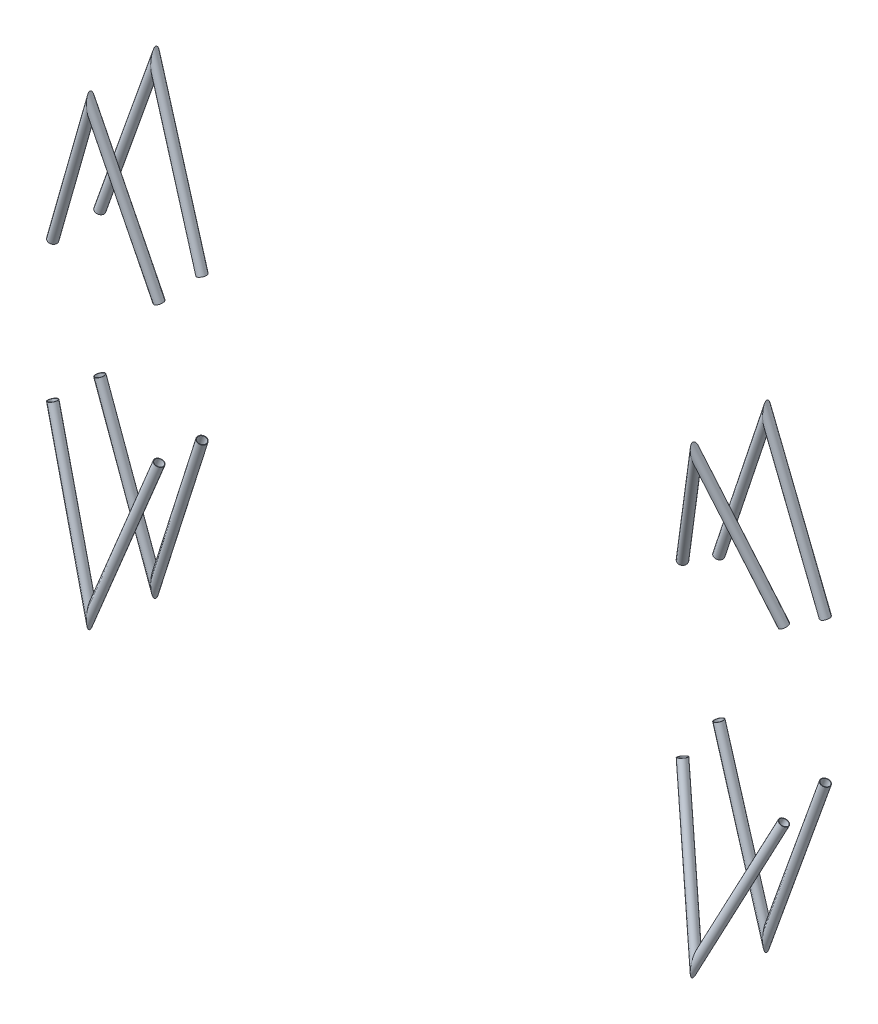
from build123d import *

# Parameters (mm, degrees)
SKETCH1_R                                   = 12.5
SKETCH1_R_2                                 = 11.3
SIZE_C_TUBING_FSAE_SIZE_C_TUBING_1_DEPTH    = 505.010497452
SKETCH1_ON_SEGMENT_2_R                      = 12.5
SKETCH1_ON_SEGMENT_2_R_2                    = 11.3
SIZE_C_TUBING_FSAE_SIZE_C_TUBING_1_2_DEPTH  = 511.58362987
SKETCH1_ON_SEGMENT_3_R                      = 12.5
SKETCH1_ON_SEGMENT_3_R_2                    = 11.3
SIZE_C_TUBING_FSAE_SIZE_C_TUBING_1_3_DEPTH  = 464.446173361
SKETCH1_ON_SEGMENT_4_R                      = 12.5
SKETCH1_ON_SEGMENT_4_R_2                    = 11.3
SIZE_C_TUBING_FSAE_SIZE_C_TUBING_1_4_DEPTH  = 460.829284715
SKETCH1_ON_SEGMENT_5_R                      = 12.5
SKETCH1_ON_SEGMENT_5_R_2                    = 11.3
SIZE_C_TUBING_FSAE_SIZE_C_TUBING_1_5_DEPTH  = 505.010497452
SKETCH1_ON_SEGMENT_6_R                      = 12.5
SKETCH1_ON_SEGMENT_6_R_2                    = 11.3
SIZE_C_TUBING_FSAE_SIZE_C_TUBING_1_6_DEPTH  = 511.58362987
SKETCH1_ON_SEGMENT_7_R                      = 12.5
SKETCH1_ON_SEGMENT_7_R_2                    = 11.3
SIZE_C_TUBING_FSAE_SIZE_C_TUBING_1_7_DEPTH  = 464.446173361
SKETCH1_ON_SEGMENT_8_R                      = 12.5
SKETCH1_ON_SEGMENT_8_R_2                    = 11.3
SIZE_C_TUBING_FSAE_SIZE_C_TUBING_1_8_DEPTH  = 460.829284715
SKETCH1_ON_SEGMENT_9_R                      = 12.5
SKETCH1_ON_SEGMENT_9_R_2                    = 11.3
SIZE_C_TUBING_FSAE_SIZE_C_TUBING_1_9_DEPTH  = 507.891829763
SKETCH1_ON_SEGMENT_10_R                     = 12.5
SKETCH1_ON_SEGMENT_10_R_2                   = 11.3
SIZE_C_TUBING_FSAE_SIZE_C_TUBING_1_10_DEPTH = 507.503818109
SKETCH1_ON_SEGMENT_11_R                     = 12.5
SKETCH1_ON_SEGMENT_11_R_2                   = 11.3
SIZE_C_TUBING_FSAE_SIZE_C_TUBING_1_11_DEPTH = 498.438104593
SKETCH1_ON_SEGMENT_12_R                     = 12.5
SKETCH1_ON_SEGMENT_12_R_2                   = 11.3
SIZE_C_TUBING_FSAE_SIZE_C_TUBING_1_12_DEPTH = 498.684378219
SKETCH1_ON_SEGMENT_13_R                     = 12.5
SKETCH1_ON_SEGMENT_13_R_2                   = 11.3
SIZE_C_TUBING_FSAE_SIZE_C_TUBING_1_13_DEPTH = 507.891829763
SKETCH1_ON_SEGMENT_14_R                     = 12.5
SKETCH1_ON_SEGMENT_14_R_2                   = 11.3
SIZE_C_TUBING_FSAE_SIZE_C_TUBING_1_14_DEPTH = 507.503818109
SKETCH1_ON_SEGMENT_15_R                     = 12.5
SKETCH1_ON_SEGMENT_15_R_2                   = 11.3
SIZE_C_TUBING_FSAE_SIZE_C_TUBING_1_15_DEPTH = 498.438104593
SKETCH1_ON_SEGMENT_16_R                     = 12.5
SKETCH1_ON_SEGMENT_16_R_2                   = 11.3
SIZE_C_TUBING_FSAE_SIZE_C_TUBING_1_16_DEPTH = 498.684378219


with BuildPart() as part:
    # Sketch1 → Size c tubing FSAE SIZE C TUBING(1) (new body)
    with BuildSketch(Plane(origin=(1850, 200.026372422, 102.755785644), x_dir=(0.9088891872827365, 0.2797314168806091, 0.3093069343718206), z_dir=(-0.30930693437182055, 0.9496443333386347, 0.050048581471671336))):
        Circle(SKETCH1_R)
        Circle(SKETCH1_R_2, mode=Mode.SUBTRACT)
    extrude(amount=SIZE_C_TUBING_FSAE_SIZE_C_TUBING_1_DEPTH)

    # Size c tubing FSAE SIZE C TUBING(1) mitre
    split(bisect_by=Plane(origin=(1709.824911385, 630.396544527, 125.43734743), x_dir=(0.020662652, 0.999786505, 0), z_dir=(0.999766754, -0.020662244, 0.006285594)), keep=Keep.TOP)


with BuildPart() as body_2:
    # Sketch1 on segment 2 (carried to segment 2) → Size c tubing FSAE SIZE C TUBING_1 2 (new body)
    with BuildSketch(Plane(origin=(1727.838634974, 678.903183787, 128.244868038), x_dir=(-0.900371695, 0.317123529, 0.297932003), z_dir=(-0.34762378, -0.936067504, -0.054178744))):
        Circle(SKETCH1_ON_SEGMENT_2_R)
        Circle(SKETCH1_ON_SEGMENT_2_R_2, mode=Mode.SUBTRACT)
    extrude(amount=SIZE_C_TUBING_FSAE_SIZE_C_TUBING_1_2_DEPTH)

    # Size c tubing FSAE SIZE C TUBING_1 2 mit
    split(bisect_by=Plane(origin=(1709.824911385, 630.396544527, 125.43734743), x_dir=(-0.020662652, -0.999786505, 0), z_dir=(-0.999766754, 0.020662244, -0.006285594)), keep=Keep.TOP)


with BuildPart() as body_3:
    # Sketch1 on segment 3 (carried to segment 3) → Size c tubing FSAE SIZE C TUBING_1 3 (new body)
    with BuildSketch(Plane(origin=(1850, 238.5, 218.650822795), x_dir=(0.89733271, 0.310591259, 0.313571487), z_dir=(-0.383490402, 0.900367222, 0.205606363))):
        Circle(SKETCH1_ON_SEGMENT_3_R)
        Circle(SKETCH1_ON_SEGMENT_3_R_2, mode=Mode.SUBTRACT)
    extrude(amount=SIZE_C_TUBING_FSAE_SIZE_C_TUBING_1_3_DEPTH)

    # Size c tubing FSAE SIZE C TUBING_1 3 mit
    split(bisect_by=Plane(origin=(1689.779082802, 614.670202253, 304.5524251), x_dir=(-0.010904866, 0.99994054, 0), z_dir=(0.998262285, 0.010886564, 0.057912808)), keep=Keep.TOP)


with BuildPart() as body_4:
    # Sketch1 on segment 4 (carried to segment 4) → Size c tubing FSAE SIZE C TUBING_1 4 (new body)
    with BuildSketch(Plane(origin=(1705.5226414, 657.038899366, 316.095100127), x_dir=(-0.887213955, 0.394737204, -0.238817792), z_dir=(-0.337484284, -0.908229822, -0.247432713))):
        Circle(SKETCH1_ON_SEGMENT_4_R)
        Circle(SKETCH1_ON_SEGMENT_4_R_2, mode=Mode.SUBTRACT)
    extrude(amount=SIZE_C_TUBING_FSAE_SIZE_C_TUBING_1_4_DEPTH)

    # Size c tubing FSAE SIZE C TUBING_1 4 mit
    split(bisect_by=Plane(origin=(1689.779082802, 614.670202253, 304.5524251), x_dir=(0.010904866, -0.99994054, 0), z_dir=(-0.998262285, -0.010886564, -0.057912808)), keep=Keep.TOP)


with BuildPart() as body_5:
    # Sketch1 on segment 5 (carried to segment 5) → Size c tubing FSAE SIZE C TUBING_1 5 (new body)
    with BuildSketch(Plane(origin=(1850, -200.026372422, 102.755785644), x_dir=(-0.76496698, 0.279731417, 0.580151579), z_dir=(-0.309306934, -0.949644333, 0.050048581))):
        Circle(SKETCH1_ON_SEGMENT_5_R)
        Circle(SKETCH1_ON_SEGMENT_5_R_2, mode=Mode.SUBTRACT)
    extrude(amount=SIZE_C_TUBING_FSAE_SIZE_C_TUBING_1_5_DEPTH)

    # Size c tubing FSAE SIZE C TUBING_1 5 mit
    split(bisect_by=Plane(origin=(1709.824911385, -630.396544527, 125.43734743), x_dir=(-0.020662652, 0.999786505, 0), z_dir=(0.999766754, 0.020662244, 0.006285594)), keep=Keep.TOP)


with BuildPart() as body_6:
    # Sketch1 on segment 6 (carried to segment 6) → Size c tubing FSAE SIZE C TUBING_1 6 (new body)
    with BuildSketch(Plane(origin=(1727.838634974, -678.903183787, 128.244868038), x_dir=(0.885540462, 0.346753657, 0.30916014), z_dir=(-0.34762378, 0.936067504, -0.054178744))):
        Circle(SKETCH1_ON_SEGMENT_6_R)
        Circle(SKETCH1_ON_SEGMENT_6_R_2, mode=Mode.SUBTRACT)
    extrude(amount=SIZE_C_TUBING_FSAE_SIZE_C_TUBING_1_6_DEPTH)

    # Size c tubing FSAE SIZE C TUBING_1 6 mit
    split(bisect_by=Plane(origin=(1709.824911385, -630.396544527, 125.43734743), x_dir=(0.020662652, -0.999786505, 0), z_dir=(-0.999766754, -0.020662244, -0.006285594)), keep=Keep.TOP)


with BuildPart() as body_7:
    # Sketch1 on segment 7 (carried to segment 7) → Size c tubing FSAE SIZE C TUBING_1 7 (new body)
    with BuildSketch(Plane(origin=(1850, -238.5, 218.650822795), x_dir=(-0.449031759, 0.376317269, 0.810404709), z_dir=(-0.383490402, -0.900367222, 0.205606363))):
        Circle(SKETCH1_ON_SEGMENT_7_R)
        Circle(SKETCH1_ON_SEGMENT_7_R_2, mode=Mode.SUBTRACT)
    extrude(amount=SIZE_C_TUBING_FSAE_SIZE_C_TUBING_1_7_DEPTH)

    # Size c tubing FSAE SIZE C TUBING_1 7 mit
    split(bisect_by=Plane(origin=(1689.779082802, -614.670202253, 304.5524251), x_dir=(0.010904866, 0.99994054, 0), z_dir=(0.998262285, -0.010886564, 0.057912808)), keep=Keep.TOP)


with BuildPart() as body_8:
    # Sketch1 on segment 8 (carried to segment 8) → Size c tubing FSAE SIZE C TUBING_1 8 (new body)
    with BuildSketch(Plane(origin=(1705.5226414, -657.038899366, 316.095100127), x_dir=(0.866131077, 0.402551866, 0.296258253), z_dir=(-0.337484284, 0.908229822, -0.247432713))):
        Circle(SKETCH1_ON_SEGMENT_8_R)
        Circle(SKETCH1_ON_SEGMENT_8_R_2, mode=Mode.SUBTRACT)
    extrude(amount=SIZE_C_TUBING_FSAE_SIZE_C_TUBING_1_8_DEPTH)

    # Size c tubing FSAE SIZE C TUBING_1 8 mit
    split(bisect_by=Plane(origin=(1689.779082802, -614.670202253, 304.5524251), x_dir=(-0.010904866, -0.99994054, 0), z_dir=(-0.998262285, 0.010886564, -0.057912808)), keep=Keep.TOP)


with BuildPart() as body_9:
    # Sketch1 on segment 9 (carried to segment 9) → Size c tubing FSAE SIZE C TUBING_1 9 (new body)
    with BuildSketch(Plane(origin=(150, -200, 144.906781001), x_dir=(-0.896045491, 0.297315541, 0.329705849), z_dir=(-0.328799483, -0.943427741, -0.042836864))):
        Circle(SKETCH1_ON_SEGMENT_9_R)
        Circle(SKETCH1_ON_SEGMENT_9_R_2, mode=Mode.SUBTRACT)
    extrude(amount=SIZE_C_TUBING_FSAE_SIZE_C_TUBING_1_9_DEPTH)

    # Size c tubing FSAE SIZE C TUBING_1 9 mit
    split(bisect_by=Plane(origin=(0, -630.396544527, 125.36438514), x_dir=(0.001220721, 0.999999255, 0), z_dir=(0.998875011, -0.001219349, 0.047404919)), keep=Keep.TOP)


with BuildPart() as body_10:
    # Sketch1 on segment 10 (carried to segment 10) → Size c tubing FSAE SIZE C TUBING_1 10 (new body)
    with BuildSketch(Plane(origin=(17.009037437, -679.200750785, 124.764041342), x_dir=(0.898870375, 0.309453827, 0.310274681), z_dir=(-0.329079371, 0.944230829, 0.011615046))):
        Circle(SKETCH1_ON_SEGMENT_10_R)
        Circle(SKETCH1_ON_SEGMENT_10_R_2, mode=Mode.SUBTRACT)
    extrude(amount=SIZE_C_TUBING_FSAE_SIZE_C_TUBING_1_10_DEPTH)

    # Size c tubing FSAE SIZE C TUBING_1 10 mi
    split(bisect_by=Plane(origin=(0, -630.396544527, 125.36438514), x_dir=(-0.001220721, -0.999999255, 0), z_dir=(-0.998875011, 0.001219349, -0.047404919)), keep=Keep.TOP)


with BuildPart() as body_11:
    # Sketch1 on segment 11 (carried to segment 11) → Size c tubing FSAE SIZE C TUBING_1 11 (new body)
    with BuildSketch(Plane(origin=(150, -194.756208727, 264.899721344), x_dir=(-0.688598021, 0.308816552, 0.656098394), z_dir=(-0.335037494, -0.937912881, 0.089829312))):
        Circle(SKETCH1_ON_SEGMENT_11_R)
        Circle(SKETCH1_ON_SEGMENT_11_R_2, mode=Mode.SUBTRACT)
    extrude(amount=SIZE_C_TUBING_FSAE_SIZE_C_TUBING_1_11_DEPTH)

    # Size c tubing FSAE SIZE C TUBING_1 11 mi
    split(bisect_by=Plane(origin=(0, -614.670202253, 305.117299862), x_dir=(-0.000769732, 0.999999704, 0), z_dir=(0.999961224, 0.000769702, 0.008772539)), keep=Keep.TOP)


with BuildPart() as body_12:
    # Sketch1 on segment 12 (carried to segment 12) → Size c tubing FSAE SIZE C TUBING_1 12 (new body)
    with BuildSketch(Plane(origin=(16.986109954, -662.221570689, 309.97218926), x_dir=(0.885659092, 0.34778305, 0.307660402), z_dir=(-0.3348533, 0.937397244, -0.095706182))):
        Circle(SKETCH1_ON_SEGMENT_12_R)
        Circle(SKETCH1_ON_SEGMENT_12_R_2, mode=Mode.SUBTRACT)
    extrude(amount=SIZE_C_TUBING_FSAE_SIZE_C_TUBING_1_12_DEPTH)

    # Size c tubing FSAE SIZE C TUBING_1 12 mi
    split(bisect_by=Plane(origin=(0, -614.670202253, 305.117299862), x_dir=(0.000769732, -0.999999704, 0), z_dir=(-0.999961224, -0.000769702, -0.008772539)), keep=Keep.TOP)


with BuildPart() as body_13:
    # Sketch1 on segment 13 (carried to segment 13) → Size c tubing FSAE SIZE C TUBING_1 13 (new body)
    with BuildSketch(Plane(origin=(150, 200, 144.906781001), x_dir=(0.893480552, 0.325444259, 0.309481079), z_dir=(-0.328799483, 0.943427741, -0.042836864))):
        Circle(SKETCH1_ON_SEGMENT_13_R)
        Circle(SKETCH1_ON_SEGMENT_13_R_2, mode=Mode.SUBTRACT)
    extrude(amount=SIZE_C_TUBING_FSAE_SIZE_C_TUBING_1_13_DEPTH)

    # Size c tubing FSAE SIZE C TUBING_1 13 mi
    split(bisect_by=Plane(origin=(0, 630.396544527, 125.36438514), x_dir=(-0.001220721, 0.999999255, 0), z_dir=(0.998875011, 0.001219349, 0.047404919)), keep=Keep.TOP)


with BuildPart() as body_14:
    # Sketch1 on segment 14 (carried to segment 14) → Size c tubing FSAE SIZE C TUBING_1 14 (new body)
    with BuildSketch(Plane(origin=(17.009037437, 679.200750785, 124.764041342), x_dir=(-0.828060211, 0.294460717, 0.477084032), z_dir=(-0.329079371, -0.944230829, 0.011615046))):
        Circle(SKETCH1_ON_SEGMENT_14_R)
        Circle(SKETCH1_ON_SEGMENT_14_R_2, mode=Mode.SUBTRACT)
    extrude(amount=SIZE_C_TUBING_FSAE_SIZE_C_TUBING_1_14_DEPTH)

    # Size c tubing FSAE SIZE C TUBING_1 14 mi
    split(bisect_by=Plane(origin=(0, 630.396544527, 125.36438514), x_dir=(0.001220721, -0.999999255, 0), z_dir=(-0.998875011, -0.001219349, -0.047404919)), keep=Keep.TOP)


with BuildPart() as body_15:
    # Sketch1 on segment 15 (carried to segment 15) → Size c tubing FSAE SIZE C TUBING_1 15 (new body)
    with BuildSketch(Plane(origin=(150, 194.756208727, 264.899721344), x_dir=(0.904258932, 0.293295391, 0.310312096), z_dir=(-0.335037494, 0.937912881, 0.089829312))):
        Circle(SKETCH1_ON_SEGMENT_15_R)
        Circle(SKETCH1_ON_SEGMENT_15_R_2, mode=Mode.SUBTRACT)
    extrude(amount=SIZE_C_TUBING_FSAE_SIZE_C_TUBING_1_15_DEPTH)

    # Size c tubing FSAE SIZE C TUBING_1 15 mi
    split(bisect_by=Plane(origin=(0, 614.670202253, 305.117299862), x_dir=(0.000769732, 0.999999704, 0), z_dir=(0.999961224, -0.000769702, 0.008772539)), keep=Keep.TOP)


with BuildPart() as body_16:
    # Sketch1 on segment 16 (carried to segment 16) → Size c tubing FSAE SIZE C TUBING_1 16 (new body)
    with BuildSketch(Plane(origin=(16.986109954, 662.221570689, 309.97218926), x_dir=(-0.932184485, 0.314734809, 0.178812994), z_dir=(-0.3348533, -0.937397244, -0.095706182))):
        Circle(SKETCH1_ON_SEGMENT_16_R)
        Circle(SKETCH1_ON_SEGMENT_16_R_2, mode=Mode.SUBTRACT)
    extrude(amount=SIZE_C_TUBING_FSAE_SIZE_C_TUBING_1_16_DEPTH)

    # Size c tubing FSAE SIZE C TUBING_1 16 mi
    split(bisect_by=Plane(origin=(0, 614.670202253, 305.117299862), x_dir=(-0.000769732, -0.999999704, 0), z_dir=(-0.999961224, 0.000769702, -0.008772539)), keep=Keep.TOP)


solid = Compound([part.part, body_2.part, body_3.part, body_4.part, body_5.part, body_6.part, body_7.part, body_8.part, body_9.part, body_10.part, body_11.part, body_12.part, body_13.part, body_14.part, body_15.part, body_16.part])
